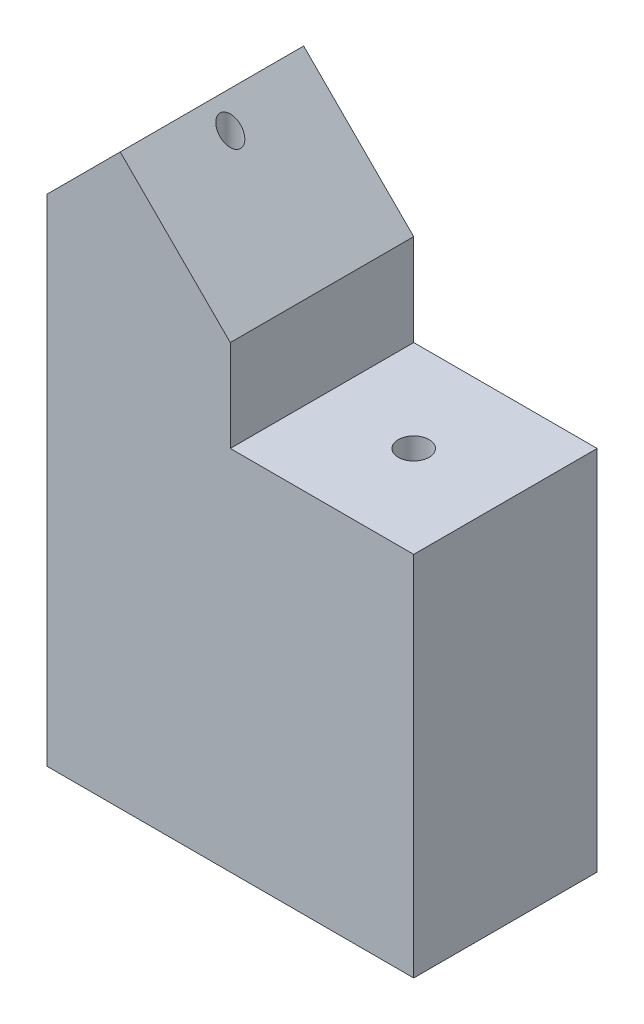
from build123d import *

# Parameters (mm, degrees)
SKETCH1_W               = 10
SKETCH1_H               = 5
BOSS_EXTRUDE1_DEPTH     = 20
SKETCH2_R               = 0.42
SKETCH2_R_2             = 0.28
CUT_EXTRUDE1_DEPTH      = 21
CUT_EXTRUDE2_DEPTH      = 3.5
CUT_EXTRUDE2_DEPTH_BACK = 3.5
CHAMFER1_SIZE2          = 2.828427125
CHAMFER1_SIZE           = 4


with BuildPart() as part:
    # Sketch1 → Boss-Extrude1 (new body)
    with BuildSketch(Plane(origin=(0, 0, 0), x_dir=(1, 0, 0), z_dir=(0, 1, 0))):
        Rectangle(SKETCH1_W, SKETCH1_H)
    extrude(amount=BOSS_EXTRUDE1_DEPTH)

    # Sketch2 → Cut-Extrude1 (cut, through all)
    with BuildSketch(Plane.XZ):
        with Locations((2.5, 0)):
            Circle(SKETCH2_R)
        with Locations((-2.5, 0)):
            Circle(SKETCH2_R_2)
    extrude(amount=-CUT_EXTRUDE1_DEPTH, mode=Mode.SUBTRACT)

    # Sketch3 → Cut-Extrude2 (cut, two sides)
    with BuildSketch(Plane.XY) as cut_extrude2_sk:
        Polygon((-5, 17.5), (0, 12.5), (0, 10), (5, 10), (5, 20), (-5, 20), align=None)
    extrude(amount=CUT_EXTRUDE2_DEPTH, mode=Mode.SUBTRACT)
    extrude(cut_extrude2_sk.sketch, amount=-CUT_EXTRUDE2_DEPTH_BACK, mode=Mode.SUBTRACT)

    # Chamfer1
    chamfer1_edges = [part.edges().sort_by_distance(p)[0] for p in [
        (-5, 17.5, 0),
    ]]
    chamfer(chamfer1_edges, length=CHAMFER1_SIZE, length2=CHAMFER1_SIZE2)


solid = part.part
